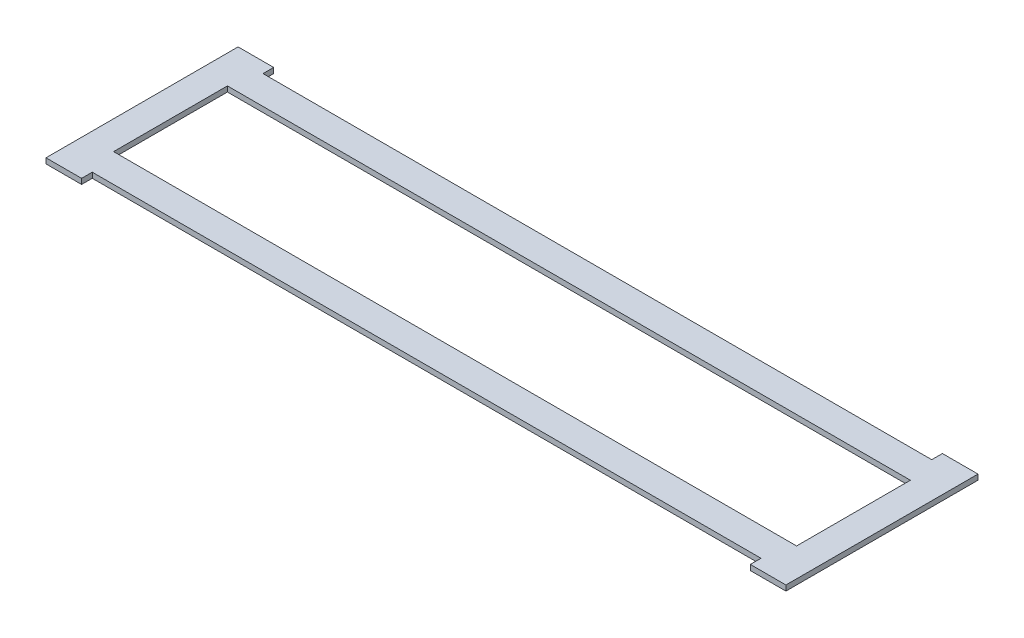
from build123d import *

# Parameters (mm, degrees)
CROQUIS1_W              = 416
CROQUIS1_H              = 96
CROQUIS1_W_2            = 384
CROQUIS1_H_2            = 64
CROQUIS1_W_3            = 20.00615983
CROQUIS1_H_3            = 6
SALIENTE_EXTRUIR1_DEPTH = 3


with BuildPart() as part:
    # Croquis1 → Saliente-Extruir1 (new body)
    with BuildSketch(Plane(origin=(0, 0, 0), x_dir=(1, 0, 0), z_dir=(0, 1, 0))):
        Rectangle(CROQUIS1_W, CROQUIS1_H)
        Rectangle(CROQUIS1_W_2, CROQUIS1_H_2, mode=Mode.SUBTRACT)
        with Locations((197.996920085, -51)):
            Rectangle(CROQUIS1_W_3, CROQUIS1_H_3)
        with Locations((197.996920085, 51)):
            Rectangle(CROQUIS1_W_3, CROQUIS1_H_3)
        with Locations((-197.996920085, 51)):
            Rectangle(CROQUIS1_W_3, CROQUIS1_H_3)
        with Locations((-197.996920085, -51)):
            Rectangle(CROQUIS1_W_3, CROQUIS1_H_3)
    extrude(amount=SALIENTE_EXTRUIR1_DEPTH)


solid = part.part
